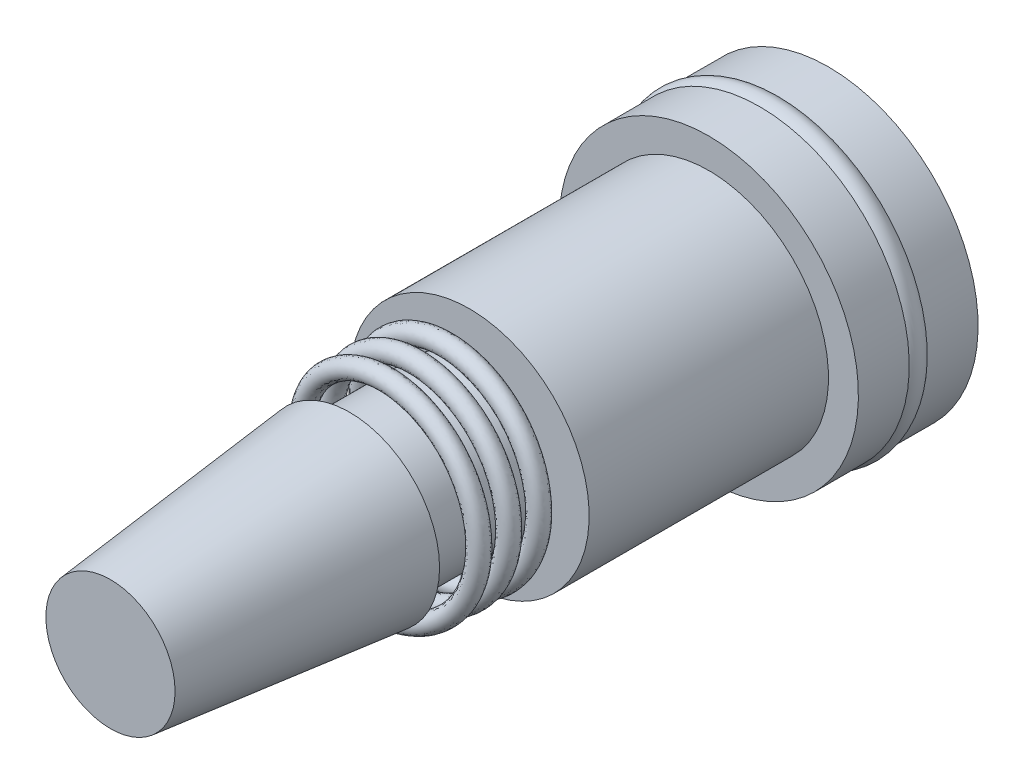
from build123d import *

# Parameters (mm, degrees)
SKETCH1_R           = 0.75
BOSS_EXTRUDE1_DEPTH = 2
BOSS_EXTRUDE1_TAPER = 6
SKETCH2_R           = 0.625
BOSS_EXTRUDE2_DEPTH = 1
SKETCH3_R           = 1
BOSS_EXTRUDE3_DEPTH = 2
SKETCH4_R           = 1.25
BOSS_EXTRUDE4_DEPTH = 1
SKETCH6_R           = 0.125
SKETCH6_2_R         = 0.125
SWEEP2_PITCH        = 0.25
SWEEP2_HEIGHT       = 0.75
SWEEP2_RADIUS       = 0.81
SWEEP2_START_ANGLE  = -180
SKETCH10_R          = 0.077696303


with BuildPart() as part:
    # Sketch1 → Boss-Extrude1 (new body)
    with BuildSketch(Plane.XY):
        Circle(SKETCH1_R)
    extrude(amount=BOSS_EXTRUDE1_DEPTH, taper=BOSS_EXTRUDE1_TAPER)

    # Sketch2 → Boss-Extrude2 (add)
    with BuildSketch(Plane(origin=(0, 0, 0), x_dir=(-1, 0, 0), z_dir=(0, 0, -1))):
        Circle(SKETCH2_R)
    extrude(amount=BOSS_EXTRUDE2_DEPTH)

    # Sketch3 → Boss-Extrude3 (add)
    with BuildSketch(Plane(origin=(0, 0, -1), x_dir=(-1, 0, 0), z_dir=(0, 0, -1))):
        Circle(SKETCH3_R)
    extrude(amount=BOSS_EXTRUDE3_DEPTH)

    # Sketch4 → Boss-Extrude4 (add)
    with BuildSketch(Plane(origin=(0, 0, -3), x_dir=(-1, 0, 0), z_dir=(0, 0, -1))):
        Circle(SKETCH4_R)
    extrude(amount=BOSS_EXTRUDE4_DEPTH)

    # Cut-Sweep1: sweep along a path in Sketch5
    with BuildLine(Plane(origin=(0, 0, -3.5), x_dir=(-1, 0, 0), z_dir=(0, 0, -1))) as cut_sweep1_path:
        CenterArc((0, 0), 1.25, 0, 360)
    # Sketch6 → Cut-Sweep1 (sweep, cut)
    with BuildSketch(Plane(origin=(0, 0, 0), x_dir=(0, 0, -1), z_dir=(1, 0, 0))):
        with Locations((3.5, 1.15)):
            Circle(SKETCH6_R)
    sweep(path=cut_sweep1_path.line, mode=Mode.SUBTRACT)


with BuildPart() as body_2:
    # Sweep1: sweep along a path in Sketch5_2
    with BuildLine(Plane(origin=(0, 0, -3.5), x_dir=(-1, 0, 0), z_dir=(0, 0, -1))) as sweep1_path:
        CenterArc((0, 0), 1.25, 0, 360)
    # Sketch6_2 → Sweep1 (sweep)
    with BuildSketch(Plane(origin=(0, 0, 0), x_dir=(0, 0, -1), z_dir=(1, 0, 0))):
        with Locations((3.5, 1.15)):
            Circle(SKETCH6_2_R)
    sweep(path=sweep1_path.line)


with BuildPart() as body_3:
    # Sweep2: sweep along a helix
    with BuildLine() as sweep2_path:
        add(Helix(SWEEP2_PITCH, SWEEP2_HEIGHT, SWEEP2_RADIUS, center=(0, 0, -0.9), direction=(0, 0, 1), lefthand=True, mode=Mode.PRIVATE).rotate(Axis((0, 0, -0.9), (0, 0, 1)), SWEEP2_START_ANGLE))
    # Sketch10 → Sweep2 (sweep)
    with BuildSketch(Plane(origin=(-0.81, 0, -0.9), x_dir=(1, 0, 0), z_dir=(0, 0.998795699, 0.049062738))):
        with Locations((0.0104601, 0.002156629)):
            Circle(SKETCH10_R)
    sweep(path=sweep2_path.line, is_frenet=True)


solid = Compound([part.part, body_2.part, body_3.part])
